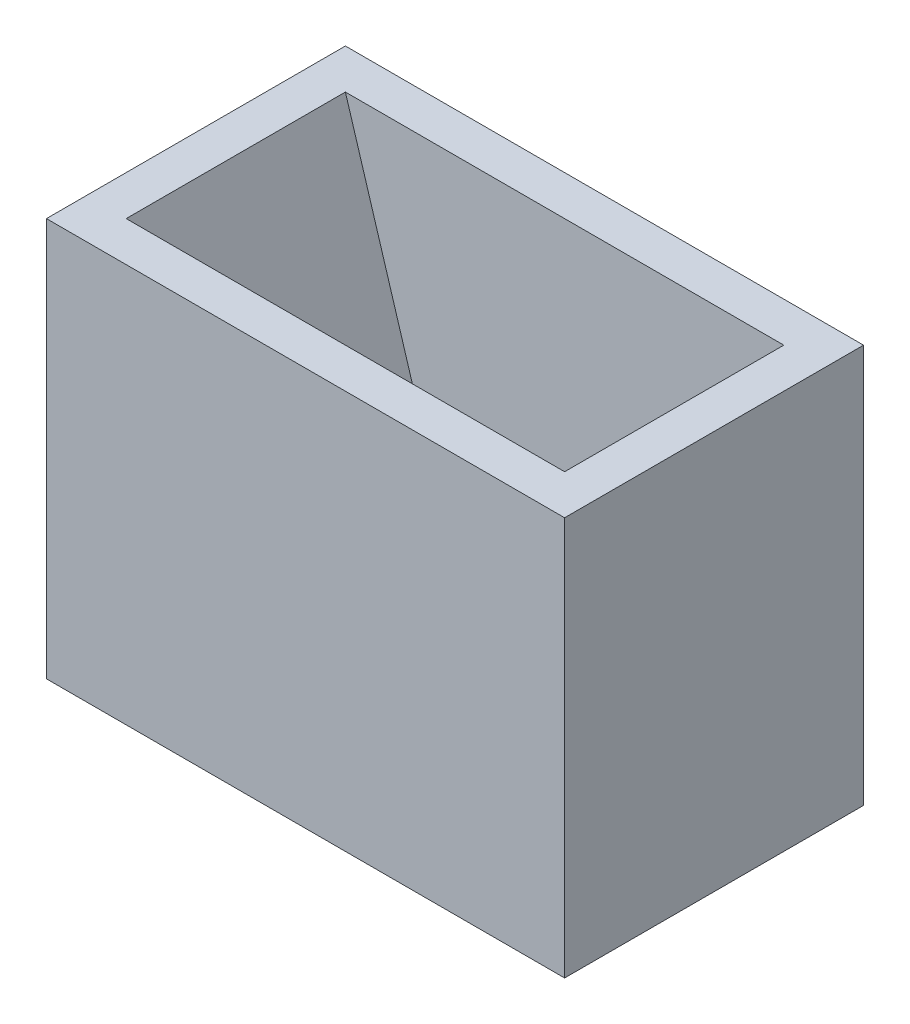
from build123d import *

# Parameters (mm, degrees)
SKETCH1_W           = 13
SKETCH1_H           = 7.5
SKETCH1_W_2         = 11
SKETCH1_H_2         = 5.5
BOSS_EXTRUDE1_DEPTH = 10
SKETCH2_W           = 13
SKETCH2_H           = 7.5
SKETCH2_R           = 2.75
BOSS_EXTRUDE2_DEPTH = 1
BOSS_EXTRUDE3_DEPTH = 3


with BuildPart() as part:
    # Sketch1 → Boss-Extrude1 (new body)
    with BuildSketch(Plane(origin=(0, 0, 0), x_dir=(1, 0, 0), z_dir=(0, 1, 0))):
        Rectangle(SKETCH1_W, SKETCH1_H)
        Rectangle(SKETCH1_W_2, SKETCH1_H_2, mode=Mode.SUBTRACT)
    extrude(amount=BOSS_EXTRUDE1_DEPTH)

    # Sketch2 → Boss-Extrude2 (add)
    with BuildSketch(Plane.XZ):
        Rectangle(SKETCH2_W, SKETCH2_H)
        Circle(SKETCH2_R, mode=Mode.SUBTRACT)
    extrude(amount=-BOSS_EXTRUDE2_DEPTH)

    # Sketch4 → Boss-Extrude3 (add, symmetric)
    with BuildSketch(Plane.XY):
        Polygon((-5.5, 10), (-2.75, 1), (-5.5, 1), align=None)
        Polygon((5.5, 10), (2.75, 1), (5.5, 1), align=None)
    extrude(amount=BOSS_EXTRUDE3_DEPTH, both=True)


solid = part.part
